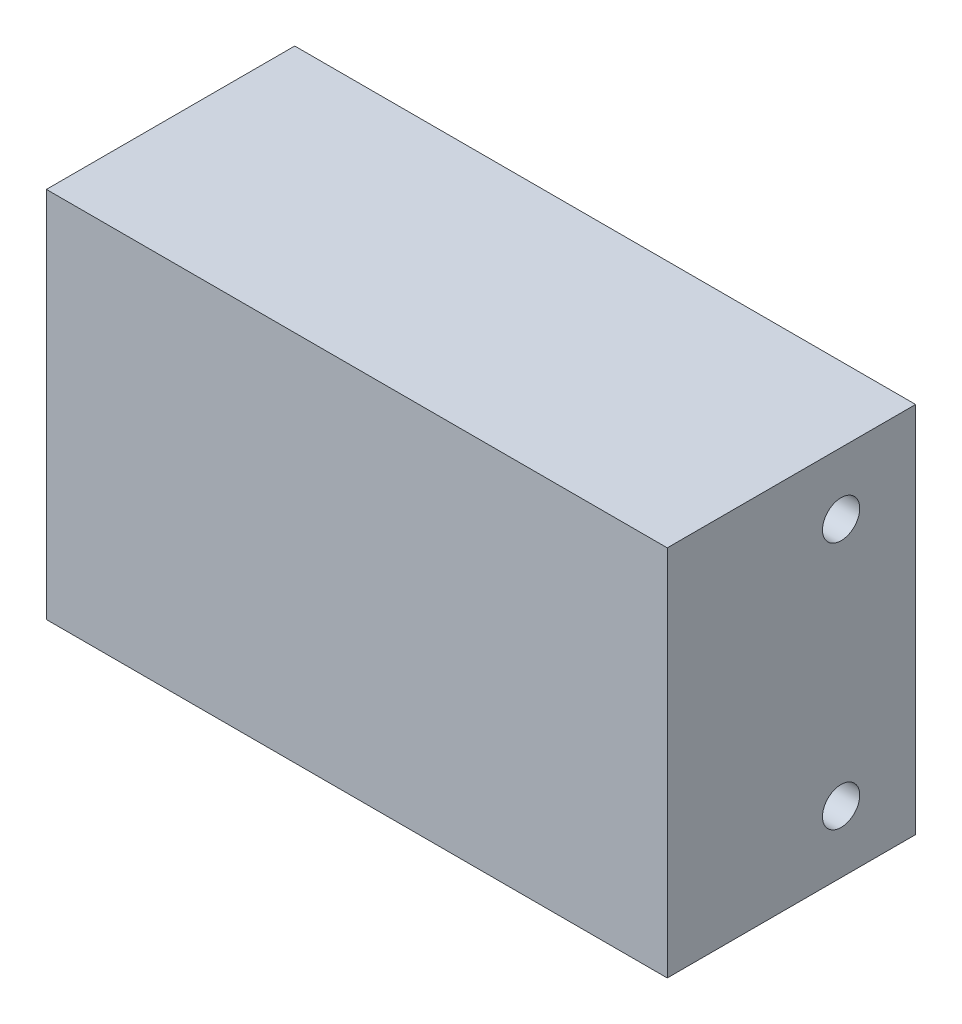
from build123d import *

# Parameters (mm, degrees)
SKETCH1_W           = 25
SKETCH1_H           = 10
BOSS_EXTRUDE1_DEPTH = 15
SKETCH2_R           = 0.75
CUT_EXTRUDE1_DEPTH  = 10
SKETCH3_R           = 0.75
CUT_EXTRUDE2_DEPTH  = 10
SKETCH4_R           = 0.75
CUT_EXTRUDE3_DEPTH  = 10


with BuildPart() as part:
    # Sketch1 → Boss-Extrude1 (new body)
    with BuildSketch(Plane(origin=(0, 0, 0), x_dir=(1, 0, 0), z_dir=(0, 1, 0))):
        with Locations((12.5, 5)):
            Rectangle(SKETCH1_W, SKETCH1_H)
    extrude(amount=BOSS_EXTRUDE1_DEPTH)

    # Sketch2 → Cut-Extrude1 (cut)
    with BuildSketch(Plane.XZ):
        with Locations((7.5, -4)):
            Circle(SKETCH2_R)
        with Locations((17.5, -4)):
            Circle(SKETCH2_R)
    extrude(amount=-CUT_EXTRUDE1_DEPTH, mode=Mode.SUBTRACT)

    # Sketch3 → Cut-Extrude2 (cut)
    with BuildSketch(Plane.ZY):
        with Locations((-7, 10.5)):
            Circle(SKETCH3_R)
        with Locations((-7, 4.5)):
            Circle(SKETCH3_R)
    extrude(amount=-CUT_EXTRUDE2_DEPTH, mode=Mode.SUBTRACT)

    # Sketch4 → Cut-Extrude3 (cut)
    with BuildSketch(Plane(origin=(25, 0, 0), x_dir=(0, 0, -1), z_dir=(1, 0, 0))):
        with Locations((7, 12.5)):
            Circle(SKETCH4_R)
        with Locations((7, 2.5)):
            Circle(SKETCH4_R)
    extrude(amount=-CUT_EXTRUDE3_DEPTH, mode=Mode.SUBTRACT)


solid = part.part
